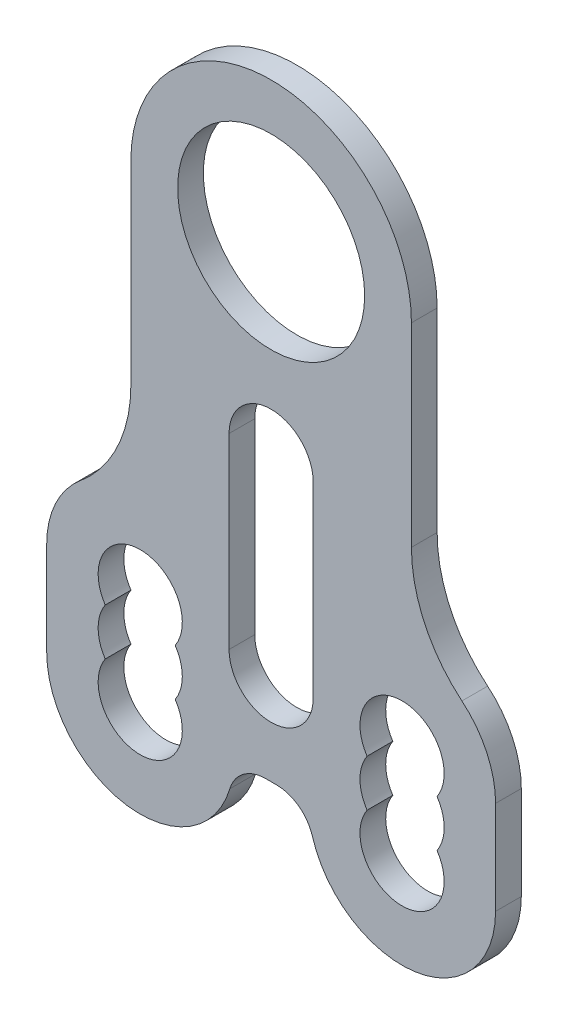
from build123d import *

# Parameters (mm, degrees)
SKETCH_1_R      = 10
EXTRUDE_1_DEPTH = 2.75


with BuildPart() as part:
    # 草图1 → 凸台-拉伸1 (new body)
    with BuildSketch(Plane.XY):
        with BuildLine():
            Line((-24, -40), (-24, -50))
            ThreePointArc((-24, -50), (-15.443695821, -59.895238369), (-4.416851525, -52.857142857))
            ThreePointArc((-4.416851525, -52.857142857), (-2.974049354, -50.792865097), (-0.583592135, -50))
            Line((-0.583592135, -50), (0.583592135, -50))
            ThreePointArc((0.583592135, -50), (2.974049354, -50.792865097), (4.416851525, -52.857142857))
            ThreePointArc((4.416851525, -52.857142857), (15.443695821, -59.895238369), (24, -50))
            Line((24, -50), (24, -40))
            ThreePointArc((24, -40), (23.055385138, -35.757359313), (20.4, -32.316250915))
            ThreePointArc((20.4, -32.316250915), (16.416922293, -27.154588318), (15, -20.790627288))
            Line((15, -20.790627288), (15, 0))
            ThreePointArc((15, 0), (0, 15), (-15, 0))
            Line((-15, 0), (-15, -20.790627288))
            ThreePointArc((-15, -20.790627288), (-16.416922293, -27.154588318), (-20.4, -32.316250915))
            ThreePointArc((-20.4, -32.316250915), (-23.055385138, -35.757359313), (-24, -40))
        make_face()
        Circle(SKETCH_1_R, mode=Mode.SUBTRACT)
        with BuildLine():
            Line((-4.5, -20), (-4.5, -40))
            ThreePointArc((-4.5, -40), (0, -44.5), (4.5, -40))
            Line((4.5, -40), (4.5, -20))
            ThreePointArc((4.5, -20), (0, -15.5), (-4.5, -20))
        make_face(mode=Mode.SUBTRACT)
        with BuildLine():
            ThreePointArc((-17.741657387, -47.5), (-14, -54.5), (-10.258342613, -47.5))
            ThreePointArc((-10.258342613, -47.5), (-9.5, -45), (-10.258342613, -42.5))
            ThreePointArc((-10.258342613, -42.5), (-14, -35.5), (-17.741657387, -42.5))
            ThreePointArc((-17.741657387, -42.5), (-18.5, -45), (-17.741657387, -47.5))
        make_face(mode=Mode.SUBTRACT)
        with BuildLine():
            ThreePointArc((10.258342613, -47.5), (9.5, -45), (10.258342613, -42.5))
            ThreePointArc((10.258342613, -42.5), (14, -35.5), (17.741657387, -42.5))
            ThreePointArc((17.741657387, -42.5), (18.5, -45), (17.741657387, -47.5))
            ThreePointArc((17.741657387, -47.5), (14, -54.5), (10.258342613, -47.5))
        make_face(mode=Mode.SUBTRACT)
    extrude(amount=EXTRUDE_1_DEPTH)


solid = part.part
